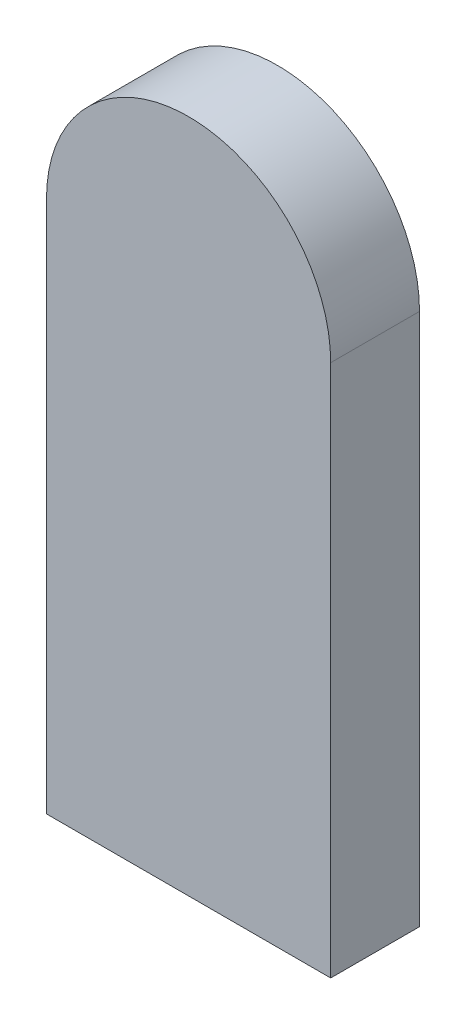
from build123d import *

# Parameters (mm, degrees)
ESTRUSIONE_ESTRUSIONE1_DEPTH = 25


with BuildPart() as part:
    # Schizzo1 → Estrusione-Estrusione1 (new body)
    with BuildSketch(Plane.XY):
        with BuildLine():
            Line((-40, 0), (-40, -150))
            Line((-40, -150), (40, -150))
            Line((40, -150), (40, 0))
            ThreePointArc((40, 0), (0, 40), (-40, 0))
        make_face()
    extrude(amount=ESTRUSIONE_ESTRUSIONE1_DEPTH)


solid = part.part
